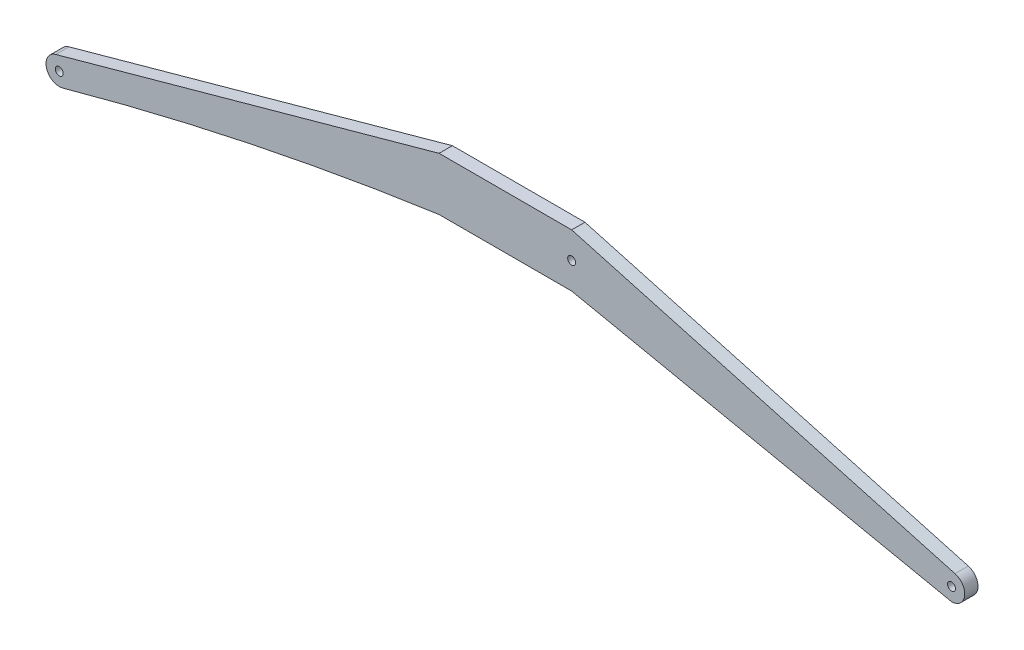
from build123d import *

# Parameters (mm, degrees)
SKETCH_1_R      = 0.3
EXTRUDE_1_DEPTH = 1


with BuildPart() as part:
    # 草图1 → 凸台-拉伸1 (new body)
    with BuildSketch(Plane.XY):
        with BuildLine():
            Line((-5, 0), (-33.91366459, -8))
            ThreePointArc((-33.91366459, -8), (-34.610786743, -9.230455486), (-33.380331256, -9.927577639))
            ThreePointArc((-33.380331256, -9.927577639), (-19.285084677, -6.509330991), (-5, -4))
            Line((-5, -4), (5, -4))
            Line((5, -4), (33.646997923, -9.96378882))
            ThreePointArc((33.646997923, -9.96378882), (34.637903776, -9.098345834), (33.91366459, -8))
            Line((33.91366459, -8), (5, 0))
            Line((5, 0), (-5, 0))
        make_face()
        with Locations((-33.646997923, -8.96378882)):
            Circle(SKETCH_1_R, mode=Mode.SUBTRACT)
        with Locations((5, -2)):
            Circle(SKETCH_1_R, mode=Mode.SUBTRACT)
        with Locations((33.646997923, -8.96378882)):
            Circle(SKETCH_1_R, mode=Mode.SUBTRACT)
    extrude(amount=EXTRUDE_1_DEPTH)


solid = part.part
